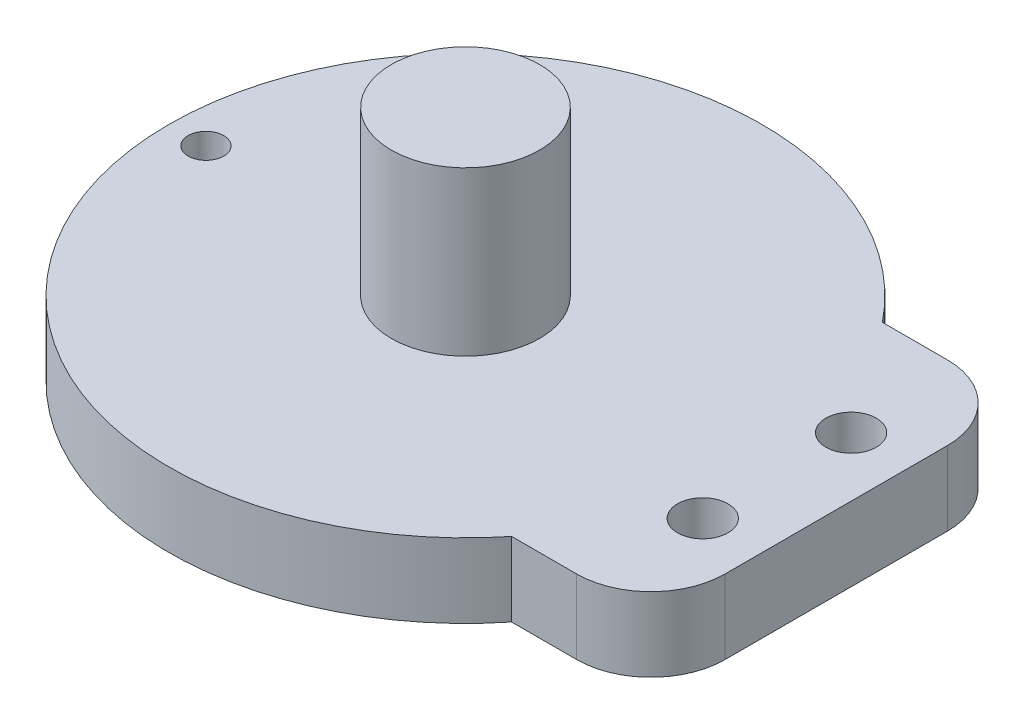
from build123d import *

# Parameters (mm, degrees)
EXTRUDE_1_DEPTH     = 5
SKETCH_2_R          = 5
EXTRUDE_2_DEPTH     = 11
CUT_EXTRUDE_1_REACH = 7
SKETCH_3_R          = 1.2
SKETCH_3_R_2        = 1.7
SKETCH_4_R          = 2
SKETCH_4_R_2        = 3
CUT_EXTRUDE_2_DEPTH = 2
FILLET_1_R          = 5


with BuildPart() as part:
    # 스케치1 → 보스-돌출1 (new body)
    with BuildSketch(Plane(origin=(0, 0, 0), x_dir=(1, 0, 0), z_dir=(0, 1, 0))):
        with BuildLine():
            Line((15.612494996, 12.5), (25, 12.5))
            Line((25, 12.5), (25, -12.5))
            Line((25, -12.5), (15.612494996, -12.5))
            ThreePointArc((15.612494996, -12.5), (-20, 0), (15.612494996, 12.5))
        make_face()
    extrude(amount=EXTRUDE_1_DEPTH)

    # 스케치2 → 보스-돌출2 (add)
    with BuildSketch(Plane(origin=(0, 5, 0), x_dir=(1, 0, 0), z_dir=(0, 1, 0))):
        Circle(SKETCH_2_R)
    extrude(amount=EXTRUDE_2_DEPTH)

    # 스케치3 → 컷-돌출1 (cut, up to next)
    with BuildSketch(Plane(origin=(0, 5, 0), x_dir=(1, 0, 0), z_dir=(0, 1, 0)), mode=Mode.PRIVATE) as cut_extrude_1_sk1:
        with Locations((-17.5, 0)):
            Circle(SKETCH_3_R)
    cut_extrude_1_tool1 = extrude(cut_extrude_1_sk1.sketch, amount=-CUT_EXTRUDE_1_REACH, mode=Mode.PRIVATE) & part.part
    add(cut_extrude_1_tool1.solids().sort_by_distance((-17.5, 5, 0))[0], mode=Mode.SUBTRACT)
    # 스케치3 → 컷-돌출1 (cut, up to next)
    with BuildSketch(Plane(origin=(0, 5, 0), x_dir=(1, 0, 0), z_dir=(0, 1, 0)), mode=Mode.PRIVATE) as cut_extrude_1_sk2:
        with Locations((21, 5)):
            Circle(SKETCH_3_R_2)
    cut_extrude_1_tool2 = extrude(cut_extrude_1_sk2.sketch, amount=-CUT_EXTRUDE_1_REACH, mode=Mode.PRIVATE) & part.part
    add(cut_extrude_1_tool2.solids().sort_by_distance((21, 5, -5))[0], mode=Mode.SUBTRACT)
    # 스케치3 → 컷-돌출1 (cut, up to next)
    with BuildSketch(Plane(origin=(0, 5, 0), x_dir=(1, 0, 0), z_dir=(0, 1, 0)), mode=Mode.PRIVATE) as cut_extrude_1_sk3:
        with Locations((21, -5)):
            Circle(SKETCH_3_R_2)
    cut_extrude_1_tool3 = extrude(cut_extrude_1_sk3.sketch, amount=-CUT_EXTRUDE_1_REACH, mode=Mode.PRIVATE) & part.part
    add(cut_extrude_1_tool3.solids().sort_by_distance((21, 5, 5))[0], mode=Mode.SUBTRACT)

    # 스케치4 → 컷-돌출2 (cut)
    with BuildSketch(Plane.XZ):
        with Locations((-17.5, 0)):
            Circle(SKETCH_4_R)
        with Locations((21, 5)):
            Circle(SKETCH_4_R_2)
        with Locations((21, -5)):
            Circle(SKETCH_4_R_2)
    extrude(amount=-CUT_EXTRUDE_2_DEPTH, mode=Mode.SUBTRACT)

    # 필렛1
    fillet_1_edges = [part.edges().sort_by_distance(p)[0] for p in [
        (25, 2.5, 12.5),
        (25, 2.5, -12.5),
    ]]
    fillet(fillet_1_edges, radius=FILLET_1_R)


solid = part.part
